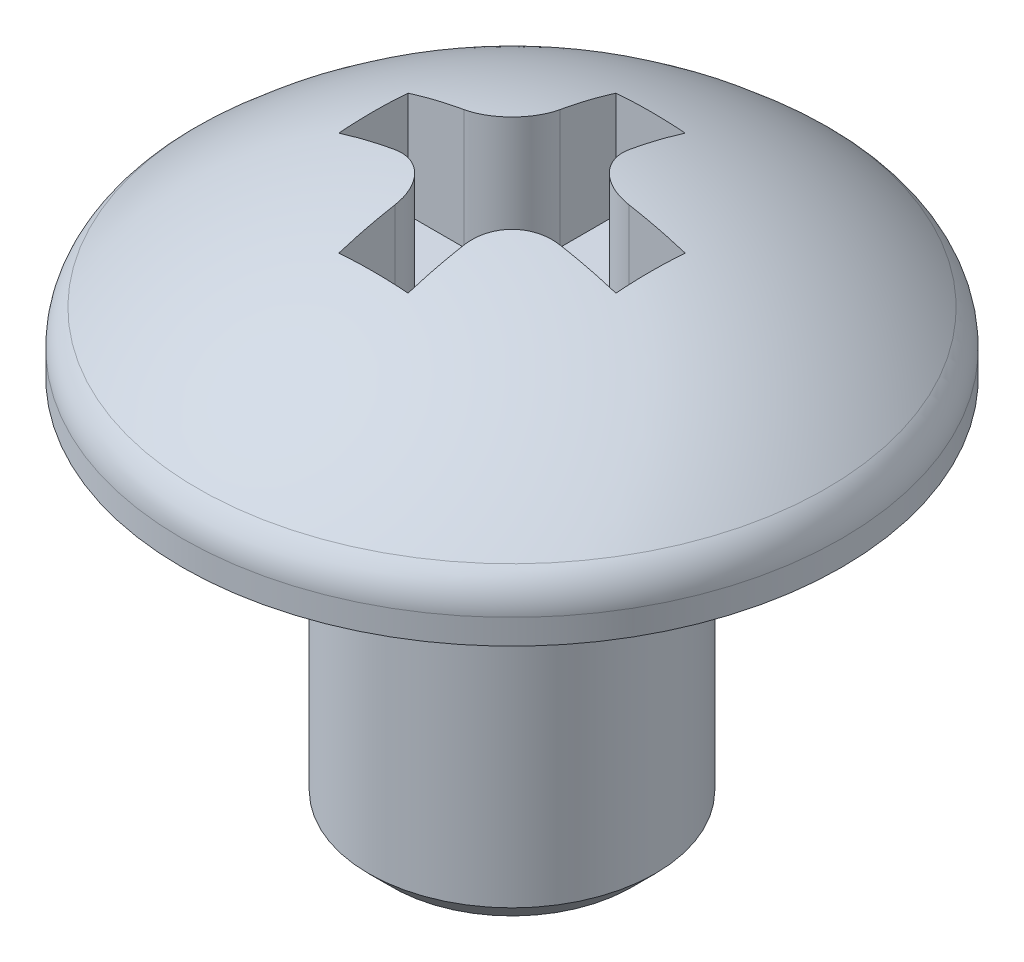
from build123d import *

# Parameters (mm, degrees)
CUT_EXTRUDE1_DEPTH = 1.34
CHAMFER1_SIZE      = 0.25
FILLET1_R          = 0.5
FILLET2_R          = 0.5


with BuildPart() as part:
    # Sketch1 → Revolve1 (revolve)
    with BuildSketch(Plane.XY):
        with BuildLine():
            Line((0, -4), (1.5, -4))
            Line((1.5, -4), (1.5, 0))
            Line((1.5, 0), (3.45, 0))
            Line((3.45, 0), (3.45, 0.475))
            ThreePointArc((3.45, 0.475), (1.866355071, 1.529728066), (0, 1.9))
            Line((0, 1.9), (0, -4))
        make_face()
    revolve(axis=Axis((0, -2.988815789, 0), (0, 1, 0)))

    # Sketch3 → Cut-Extrude1 (cut)
    with BuildSketch(Plane(origin=(0, 1.9, 0), x_dir=(-1, 0, 0), z_dir=(0, 1, 0))):
        Polygon((-0.3625, 1.45), (0.3625, 1.45), (0.3625, 0.3625), (1.45, 0.3625), (1.45, -0.3625), (0.3625, -0.3625), (0.3625, -1.45), (-0.3625, -1.45), (-0.3625, -0.3625), (-1.45, -0.3625), (-1.45, 0.3625), (-0.3625, 0.3625), align=None)
    extrude(amount=-CUT_EXTRUDE1_DEPTH, mode=Mode.SUBTRACT)

    # Chamfer1
    chamfer1_edges = [part.edges().sort_by_distance(p)[0] for p in [
        (-1.5, -4, 0),
    ]]
    chamfer(chamfer1_edges, length=CHAMFER1_SIZE)

    # Fillet1
    fillet1_edges = [part.edges().sort_by_distance(p)[0] for p in [
        (-3.45, 0.475, 0),
    ]]
    fillet(fillet1_edges, radius=FILLET1_R)

    # Fillet2
    fillet2_edges = [part.edges().sort_by_distance(p)[0] for p in [
        (0.3625, 1.216523373, 0.3625),
        (-0.3625, 1.216523373, 0.3625),
        (-0.3625, 1.216523373, -0.3625),
        (0.3625, 1.216523373, -0.3625),
    ]]
    fillet(fillet2_edges, radius=FILLET2_R)


solid = part.part
